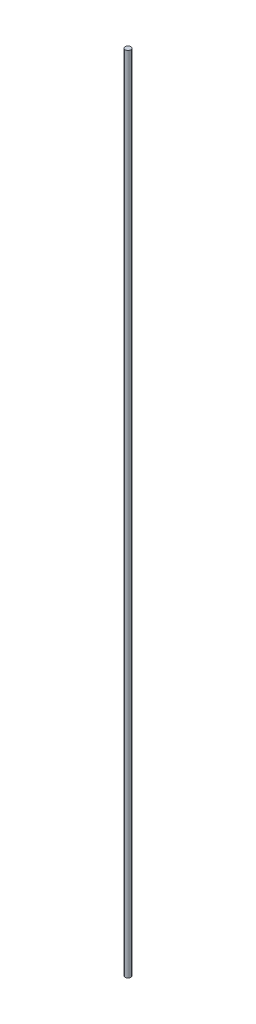
from build123d import *

# Parameters (mm, degrees)
SKETCH1_R           = 2
BOSS_EXTRUDE1_DEPTH = 588


with BuildPart() as part:
    # Sketch1 → Boss-Extrude1 (new body)
    with BuildSketch(Plane(origin=(0, 0, 0), x_dir=(1, 0, 0), z_dir=(0, 1, 0))):
        Circle(SKETCH1_R)
    extrude(amount=BOSS_EXTRUDE1_DEPTH)


solid = part.part
